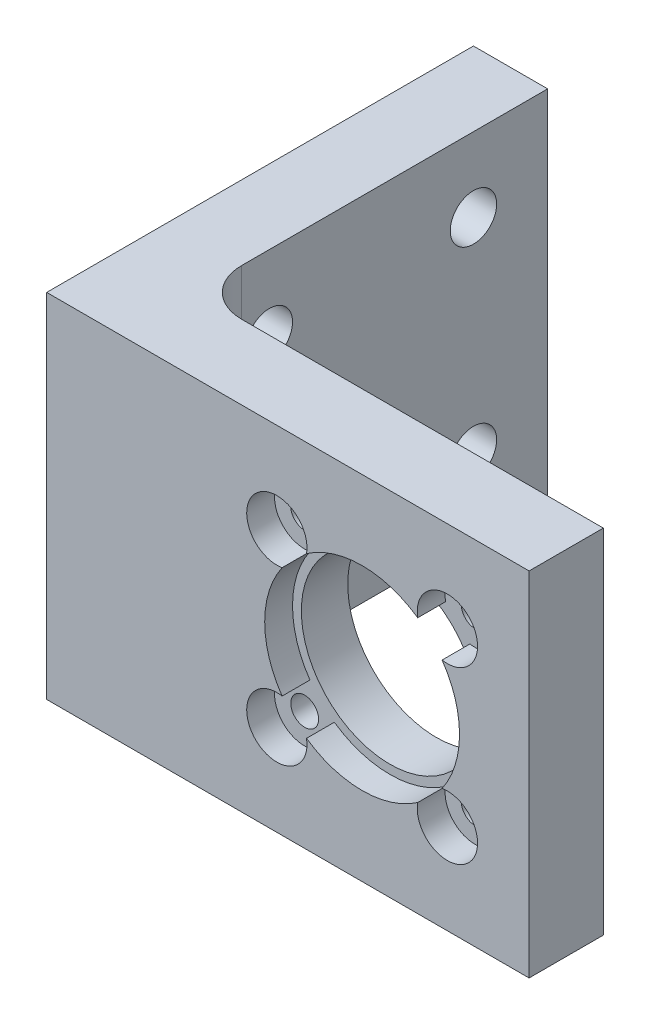
from build123d import *

# Parameters (mm, degrees)
SKETCH1_W         = 52
SKETCH1_H         = 38
SKETCH1_R         = 1.5
SKETCH1_R_2       = 9.55
FACE_IN_DEPTH     = 5
SKETCH8_W         = 8
SKETCH8_H         = 38
BOTTOM_DEPTH      = 38
FILLET1_R         = 5
SKETCH10_W        = 52
SKETCH10_H        = 38
FACE_OUT_DEPTH    = 3
SKETCH12_R        = 2.5
SCREW_HOLES_DEPTH = 8


with BuildPart() as part:
    # Sketch1 → Face_In (new body)
    with BuildSketch(Plane.XY):
        with Locations((26, 19)):
            Rectangle(SKETCH1_W, SKETCH1_H)
        with Locations((43.192388155, 28.192388155)):
            Circle(SKETCH1_R, mode=Mode.SUBTRACT)
        with Locations((43.192388155, 9.807611845)):
            Circle(SKETCH1_R, mode=Mode.SUBTRACT)
        with Locations((24.807611845, 9.807611845)):
            Circle(SKETCH1_R, mode=Mode.SUBTRACT)
        with Locations((24.807611845, 28.192388155)):
            Circle(SKETCH1_R, mode=Mode.SUBTRACT)
        with Locations((34, 19)):
            Circle(SKETCH1_R_2, mode=Mode.SUBTRACT)
    extrude(amount=FACE_IN_DEPTH)

    # Sketch8 → Bottom (add)
    with BuildSketch(Plane(origin=(0, 0, 0), x_dir=(-1, 0, 0), z_dir=(0, 0, -1))):
        with Locations((-4, 19)):
            Rectangle(SKETCH8_W, SKETCH8_H)
    extrude(amount=BOTTOM_DEPTH)

    # Fillet1
    fillet1_edges = [part.edges().sort_by_distance(p)[0] for p in [
        (8, 19, 0),
    ]]
    fillet(fillet1_edges, radius=FILLET1_R)

    # Sketch10 → Face_Out (add)
    with BuildSketch(Plane.XY.offset(5)):
        with Locations((26, 19)):
            Rectangle(SKETCH10_W, SKETCH10_H)
        with BuildLine():
            ThreePointArc((42.621806472, 24.992866856), (45.490485194, 30.490485194), (39.992866856, 27.621806472))
            ThreePointArc((39.992866856, 27.621806472), (34, 29.5), (28.007133144, 27.621806472))
            ThreePointArc((28.007133144, 27.621806472), (22.509514806, 30.490485194), (25.378193528, 24.992866856))
            ThreePointArc((25.378193528, 24.992866856), (23.5, 19), (25.378193528, 13.007133144))
            ThreePointArc((25.378193528, 13.007133144), (22.509514806, 7.509514806), (28.007133144, 10.378193528))
            ThreePointArc((28.007133144, 10.378193528), (34, 8.5), (39.992866856, 10.378193528))
            ThreePointArc((39.992866856, 10.378193528), (45.490485194, 7.509514806), (42.621806472, 13.007133144))
            ThreePointArc((42.621806472, 13.007133144), (44.5, 19), (42.621806472, 24.992866856))
        make_face(mode=Mode.SUBTRACT)
    extrude(amount=FACE_OUT_DEPTH)

    # Sketch12 → Screw Holes (cut)
    with BuildSketch(Plane.ZY):
        with Locations((-8, 30)):
            Circle(SKETCH12_R)
        with Locations((-30, 30)):
            Circle(SKETCH12_R)
        with Locations((-8, 8)):
            Circle(SKETCH12_R)
        with Locations((-30, 8)):
            Circle(SKETCH12_R)
    extrude(amount=-SCREW_HOLES_DEPTH, mode=Mode.SUBTRACT)


solid = part.part
